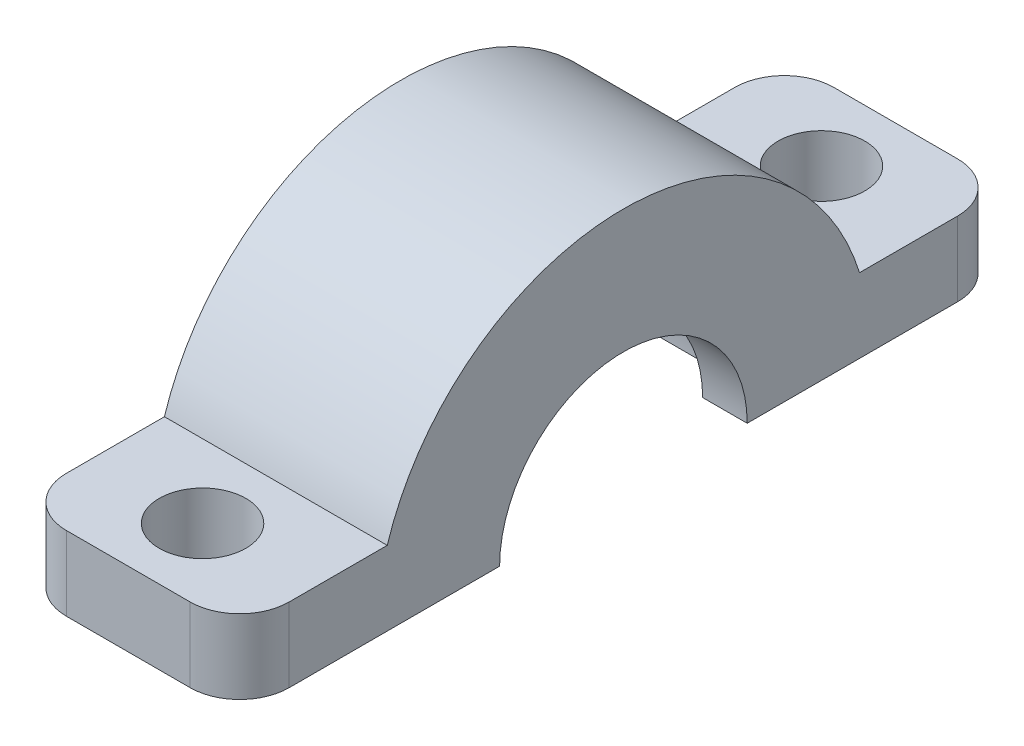
from build123d import *

# Parameters (mm, degrees)
BOSS_EXTRUDE1_DEPTH      = 4.5
BOSS_EXTRUDE1_DEPTH_BACK = 4.5
SKETCH3_R                = 1.75
CUT_EXTRUDE1_DEPTH       = 18.592612086
FILLET1_R                = 2
CUT_EXTRUDE2_DEPTH       = 2.7
CUT_EXTRUDE2_DEPTH_BACK  = 2.7
SKETCH4_R                = 6.25


with BuildPart() as part:
    # Sketch2 → Boss-Extrude1 (new, two sides: drawn at the far end of the back side and taken through both)
    with BuildSketch(Plane(origin=(0, 0, 0), x_dir=(0, 0, -1), z_dir=(1, 0, 0)).offset(-BOSS_EXTRUDE1_DEPTH_BACK)):
        with BuildLine():
            Line((9.539392014, 1.5), (15.5, 1.5))
            Line((15.5, 1.5), (15.5, -1.5))
            Line((15.5, -1.5), (5, -1.5))
            ThreePointArc((5, -1.5), (0, 3.5), (-5, -1.5))
            Line((-5, -1.5), (-15.5, -1.5))
            Line((-15.5, -1.5), (-15.5, 1.5))
            Line((-15.5, 1.5), (-9.539392014, 1.5))
            ThreePointArc((-9.539392014, 1.5), (0, 8.5), (9.539392014, 1.5))
        make_face()
    extrude(amount=BOSS_EXTRUDE1_DEPTH + BOSS_EXTRUDE1_DEPTH_BACK)

    # Sketch3 → Cut-Extrude1 (cut, through all)
    with BuildSketch(Plane(origin=(0, 1.5, 0), x_dir=(1, 0, 0), z_dir=(0, 1, 0))):
        with Locations((0, 12.5)):
            Circle(SKETCH3_R)
        with Locations((0, -12.5)):
            Circle(SKETCH3_R)
    extrude(amount=-CUT_EXTRUDE1_DEPTH, mode=Mode.SUBTRACT)

    # Fillet1
    fillet1_edges = [part.edges().sort_by_distance(p)[0] for p in [
        (4.5, 0, 15.5),
        (-4.5, 0, 15.5),
        (4.5, 0, -15.5),
        (-4.5, 0, -15.5),
    ]]
    fillet(fillet1_edges, radius=FILLET1_R)

    # Sketch4 → Cut-Extrude2 (cut, two sides: drawn at the far end of the back side and taken through both)
    with BuildSketch(Plane(origin=(0, 0, 0), x_dir=(0, 0, -1), z_dir=(1, 0, 0)).offset(-CUT_EXTRUDE2_DEPTH_BACK)):
        with Locations((0, -1.5)):
            Circle(SKETCH4_R)
    extrude(amount=CUT_EXTRUDE2_DEPTH + CUT_EXTRUDE2_DEPTH_BACK, mode=Mode.SUBTRACT)


solid = part.part
